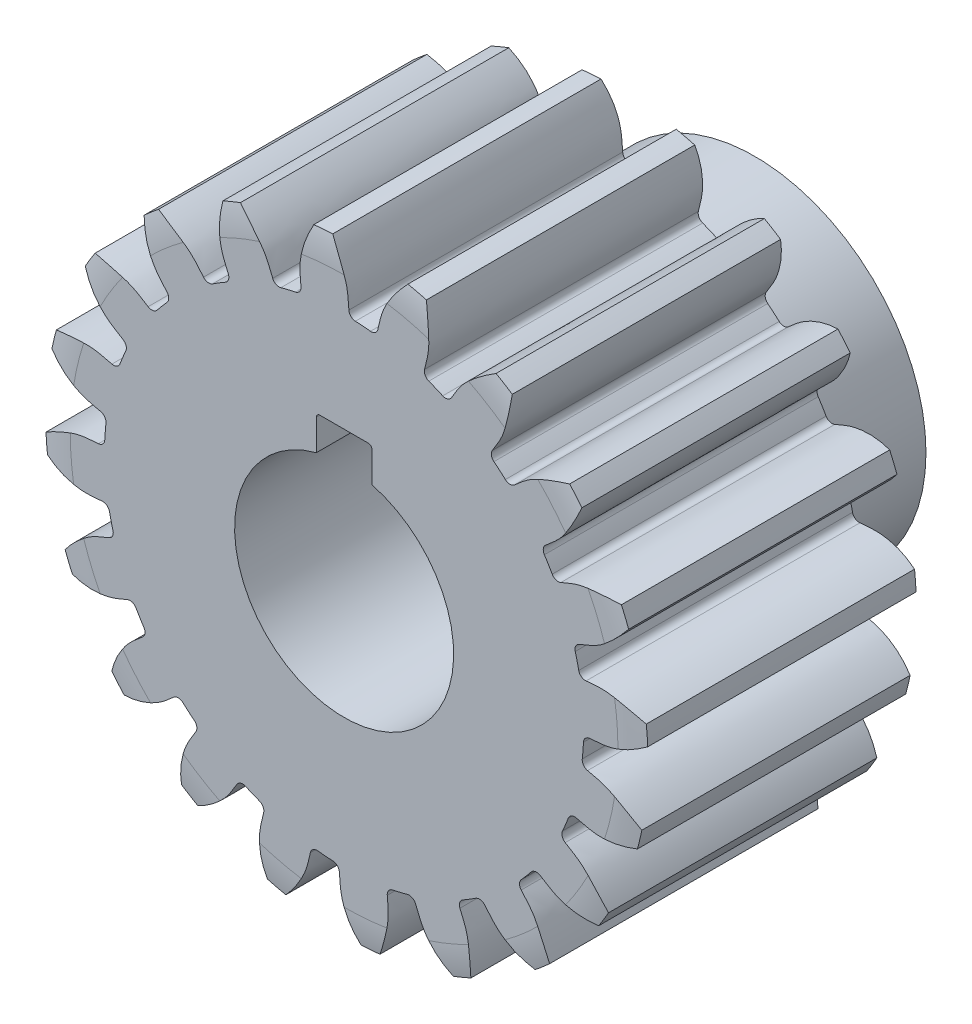
from build123d import *
from build123d.topology import SkipClean

# Parameters (mm, degrees)
SKETCH4_R                = 17.5
BOSS_EXTRUDE2_DEPTH      = 10
BOSS_EXTRUDE3_DEPTH      = 10
FILLET1_R                = 0.5
CIRPATTERN1_COUNT        = 20
FILLET1_OF_CIRPATTERN1_R = 0.5
CUT_EXTRUDE2_DEPTH       = 33.647621403
SKETCH9_R                = 8
CUT_EXTRUDE3_DEPTH       = 10
CUT_EXTRUDE4_DEPTH       = 10
BOSS_EXTRUDE4_START      = 10
SKETCH11_R               = 12.5
BOSS_EXTRUDE4_DEPTH      = 10
FILLET2_R                = 0.25
BOSS_EXTRUDE5_DEPTH      = 5
BOSS_EXTRUDE6_DEPTH      = 5
CUT_EXTRUDE5_START       = -39
CUT_EXTRUDE5_DEPTH       = 39


with BuildPart() as part:
    # Sketch4 → Boss-Extrude2 (new body)
    with BuildSketch(Plane.XY):
        Circle(SKETCH4_R)
    extrude(amount=BOSS_EXTRUDE2_DEPTH)

    # Sketch3 → Boss-Extrude3 (add)
    with BuildSketch(Plane.XY):
        with BuildLine():
            ThreePointArc((-1.03267312, 21.975749958), (-1.726100106, 21.932181342), (-2.417805488, 21.866737677))
            add(Edge.make_bspline(
                [(-3.114339189, 17.220653049), (-3.160079247, 17.912144851), (-3.298659823, 18.775292328), (-3.127363068, 19.784781367), (-3.009171352, 20.29468964), (-2.788912463, 21.006938533), (-2.572369364, 21.53562073), (-2.417805488, 21.866737677)],
                knots=[0, 0, 0, 0, 0.441913338, 0.532273099, 0.641803294, 0.770503925, 1, 1, 1, 1], degree=3))
            ThreePointArc((-3.114339189, 17.220653049), (-1.373034175, 17.44605334), (0.382092858, 17.495828218))
            add(Edge.make_bspline(
                [(0.382092858, 17.495828218), (0.31909663, 18.18596193), (0.320945035, 19.060161408), (-0.00616165, 20.030425246), (-0.202665458, 20.515566444), (-0.531632869, 21.18459029), (-0.82821408, 21.672888728), (-1.03267312, 21.975749958)],
                knots=[0, 0, 0, 0, 0.441913338, 0.532273099, 0.641803294, 0.770503925, 1, 1, 1, 1], degree=3))
        make_face()
    boss_extrude3 = extrude(amount=BOSS_EXTRUDE3_DEPTH)

    # Fillet1
    fillet1_edges = [part.edges().sort_by_distance(p)[0] for p in [
        (0.382092858, 17.495828218, 5),
        (-3.114339189, 17.220653049, 5),
    ]]
    fillet(fillet1_edges, radius=FILLET1_R)

    # CirPattern1: Boss-Extrude3 ×20 about axis
    cirpattern1_axis = Axis((0, 0, -86.49), (0, 0, 1))
    for i in range(1, CIRPATTERN1_COUNT):
        add(boss_extrude3.rotate(cirpattern1_axis, i * 360 / CIRPATTERN1_COUNT))

    # Fillet1 of CirPattern1
    fillet1_of_cirpattern1_edges = [part.edges().sort_by_distance(p)[0] for p in [
        (-5.043116348, 16.757594622, 5),
        (-8.283387026, 15.415430561, 5),
        (-9.974670188, 14.379010906, 5),
        (-12.641599227, 12.101238325, 5),
        (-13.929833812, 10.592909419, 5),
        (-15.762363616, 7.602492567, 5),
        (-16.521448249, 5.769900153, 5),
        (-17.340198032, 2.359561867, 5),
        (-17.495828218, 0.382092858, 5),
        (-17.220653049, -3.114339189, 5),
        (-16.757594622, -5.043116348, 5),
        (-15.415430561, -8.283387026, 5),
        (-14.379010906, -9.974670188, 5),
        (-12.101238325, -12.641599227, 5),
        (-10.592909419, -13.929833812, 5),
        (-7.602492567, -15.762363616, 5),
        (-5.769900153, -16.521448249, 5),
        (-2.359561867, -17.340198032, 5),
        (-0.382092858, -17.495828218, 5),
        (3.114339189, -17.220653049, 5),
        (5.043116348, -16.757594622, 5),
        (8.283387026, -15.415430561, 5),
        (9.974670188, -14.379010906, 5),
        (12.641599227, -12.101238325, 5),
        (13.929833812, -10.592909419, 5),
        (15.762363616, -7.602492567, 5),
        (16.521448249, -5.769900153, 5),
        (17.340198032, -2.359561867, 5),
        (17.495828218, -0.382092858, 5),
        (17.220653049, 3.114339189, 5),
        (16.757594622, 5.043116348, 5),
        (15.415430561, 8.283387026, 5),
        (14.379010906, 9.974670188, 5),
        (12.101238325, 12.641599227, 5),
        (10.592909419, 13.929833812, 5),
        (7.602492567, 15.762363616, 5),
        (5.769900153, 16.521448249, 5),
        (2.359561867, 17.340198032, 5),
    ]]
    fillet(fillet1_of_cirpattern1_edges, radius=FILLET1_OF_CIRPATTERN1_R)

    # Sketch5 → Cut-Extrude2 (cut, through all)
    with BuildSketch(Plane.XY):
        with BuildLine():
            Line((-1.4, 6.169696007), (1.4, 6.169696007))
            ThreePointArc((1.4, 6.169696007), (1.470710678, 6.140406685), (1.5, 6.069696007))
            Line((1.5, 6.069696007), (1.5, 4.769696007))
            ThreePointArc((1.5, 4.769696007), (0, -5), (-1.5, 4.769696007))
            Line((-1.5, 4.769696007), (-1.5, 6.069696007))
            ThreePointArc((-1.5, 6.069696007), (-1.470710678, 6.140406685), (-1.4, 6.169696007))
        make_face()
    extrude(amount=CUT_EXTRUDE2_DEPTH, mode=Mode.SUBTRACT)

    # Sketch7 → Cut-Revolve2 (revolve, cut)
    with BuildSketch(Plane(origin=(0, 0, 0), x_dir=(1, 0, 0), z_dir=(0, 1, 0))):
        with BuildLine():
            Line((-18, 0), (-20, 0))
            ThreePointArc((-20, 0), (-22.043096437, -0.210936871), (-24, -0.83484861))
            Line((-24, -0.83484861), (-24, 2))
            Line((-24, 2), (-18, 2))
            Line((-18, 2), (-18, 0))
        make_face()
    cut_revolve2 = revolve(axis=Axis((0, 0, -6.148940333), (0, 0, 1)), mode=Mode.SUBTRACT)

    # Sketch9 → Cut-Extrude3 (cut)
    with BuildSketch(Plane(origin=(0, 0, 0), x_dir=(-1, 0, 0), z_dir=(0, 0, -1))):
        Circle(SKETCH9_R)
    extrude(amount=-CUT_EXTRUDE3_DEPTH, mode=Mode.SUBTRACT)

    # Sketch10 → Cut-Extrude4 (cut)
    with BuildSketch(Plane(origin=(0, 0, 0), x_dir=(-1, 0, 0), z_dir=(0, 0, -1))):
        with BuildLine():
            Line((-2.025, 7.739468651), (-2.025, 10.239468651))
            Line((-2.025, 10.239468651), (2.025, 10.239468651))
            Line((2.025, 10.239468651), (2.025, 7.739468651))
            ThreePointArc((2.025, 7.739468651), (0, 8), (-2.025, 7.739468651))
        make_face()
    extrude(amount=-CUT_EXTRUDE4_DEPTH, mode=Mode.SUBTRACT)

    # Sketch11 → Boss-Extrude4 (add)
    with BuildSketch(Plane(origin=(0, 0, 0), x_dir=(-1, 0, 0), z_dir=(0, 0, -1)).offset(BOSS_EXTRUDE4_START)):
        with Locations(Location((0, 0, 0), (0, 0, 180))):
            Circle(SKETCH11_R)
        with BuildLine():
            Line((-2.025, 10.239468651), (-2.025, 7.739468651))
            ThreePointArc((-2.025, 7.739468651), (0, -8), (2.025, 7.739468651))
            Line((2.025, 7.739468651), (2.025, 10.239468651))
            Line((2.025, 10.239468651), (-2.025, 10.239468651))
        make_face(mode=Mode.SUBTRACT)
    extrude(amount=-BOSS_EXTRUDE4_DEPTH)

    # Fillet2
    fillet2_edges = [part.edges().sort_by_distance(p)[0] for p in [
        (2.025, 10.239468651, 0),
        (-2.025, 10.239468651, 0),
        (-12.5, 0, 0),
    ]]
    fillet(fillet2_edges, radius=FILLET2_R)

    # Sketch13 → Boss-Extrude5 (add)
    with SkipClean():  # the faces are left unmerged after this step: merging them gives an invalid solid
        with BuildSketch(Plane.XY.offset(10)):
            with BuildLine():
                ThreePointArc((-3.547592928, 17.136644491), (-3.247360967, 17.328397065), (-3.150990283, 17.671356204))
                add(Edge.make_bspline(
                    [(-2.417805488, 21.866737677), (-2.572369364, 21.53562073), (-2.788912463, 21.006938533), (-3.009171352, 20.29468964), (-3.127363068, 19.784781367), (-3.273209638, 18.925275802), (-3.200724929, 18.220572747), (-3.150990283, 17.671356204)],
                    knots=[0, 0, 0, 0, 0.229496075, 0.358196706, 0.467726901, 0.558086662, 0.904644941, 0.904644941, 0.904644941, 0.904644941], degree=3))
                ThreePointArc((-2.417805488, 21.866737677), (-1.726100106, 21.932181342), (-1.03267312, 21.975749958))
                add(Edge.make_bspline(
                    [(0.34778721, 17.946715965), (0.310993144, 18.496950953), (0.2723456, 19.20431705), (-0.00616165, 20.030425246), (-0.202665458, 20.515566444), (-0.531632869, 21.18459029), (-0.82821408, 21.672888728), (-1.03267312, 21.975749958)],
                    knots=[0.095355059, 0.095355059, 0.095355059, 0.095355059, 0.441913338, 0.532273099, 0.641803294, 0.770503925, 1, 1, 1, 1], degree=3))
                ThreePointArc((0.34778721, 17.946715965), (0.49662204, 17.623054918), (0.823154359, 17.480629763))
                ThreePointArc((0.823154359, 17.480629763), (1.373034175, 17.44605334), (1.921553003, 17.394183915))
                ThreePointArc((1.921553003, 17.394183915), (2.26634537, 17.483774671), (2.463979539, 17.780168016))
                add(Edge.make_bspline(
                    [(4.457723889, 21.543646342), (4.208404144, 21.276498277), (3.839087635, 20.840607126), (3.409511972, 20.231281915), (3.139534648, 19.782853579), (2.73522449, 19.010484278), (2.586396325, 18.317872839), (2.463979539, 17.780168016)],
                    knots=[0, 0, 0, 0, 0.229496075, 0.358196706, 0.467726901, 0.558086662, 0.904644941, 0.904644941, 0.904644941, 0.904644941], degree=3))
                ThreePointArc((4.457723889, 21.543646342), (5.135798005, 21.392138249), (5.808749701, 21.219293742))
                add(Edge.make_bspline(
                    [(5.876605518, 16.960869006), (6.011644244, 17.495543569), (6.193476392, 18.180231453), (6.183881728, 19.051970509), (6.146912376, 19.574090223), (6.040785514, 20.312026232), (5.909612537, 20.868074278), (5.808749701, 21.219293742)],
                    knots=[0.095355059, 0.095355059, 0.095355059, 0.095355059, 0.441913338, 0.532273099, 0.641803294, 0.770503925, 1, 1, 1, 1], degree=3))
                ThreePointArc((5.876605518, 16.960869006), (5.91813909, 16.607056566), (6.184677986, 16.370698159))
                ThreePointArc((6.184677986, 16.370698159), (6.696960066, 16.167891819), (7.202603938, 15.949059424))
                ThreePointArc((7.202603938, 15.949059424), (7.558206031, 15.927718596), (7.837757876, 16.148533101))
                add(Edge.make_bspline(
                    [(10.896900193, 19.111712801), (10.577229733, 18.934683931), (10.091291087, 18.634251889), (9.494448508, 18.187495357), (9.099112838, 17.844442246), (8.475915788, 17.2348141), (8.120343087, 16.622091909), (7.837757876, 16.148533101)],
                    knots=[0, 0, 0, 0, 0.229496075, 0.358196706, 0.467726901, 0.558086662, 0.904644941, 0.904644941, 0.904644941, 0.904644941], degree=3))
                ThreePointArc((10.896900193, 19.111712801), (11.494968424, 18.758083616), (12.08157163, 18.385745211))
                add(Edge.make_bspline(
                    [(10.830180734, 14.314774016), (11.123833721, 14.781550482), (11.508346561, 15.376538132), (11.768603677, 16.208576156), (11.894787599, 16.71656567), (12.021889723, 17.451179523), (12.068965104, 18.02054732), (12.08157163, 18.385745211)],
                    knots=[0.095355059, 0.095355059, 0.095355059, 0.095355059, 0.441913338, 0.532273099, 0.641803294, 0.770503925, 1, 1, 1, 1], degree=3))
                ThreePointArc((10.830180734, 14.314774016), (10.760347451, 13.96544381), (10.940802241, 13.658288558))
                ThreePointArc((10.940802241, 13.658288558), (11.365340846, 13.307104398), (11.778613816, 12.942729874))
                ThreePointArc((11.778613816, 12.942729874), (12.110216825, 12.81254645), (12.444321864, 12.936167253))
                add(Edge.make_bspline(
                    [(16.269411983, 14.808991651), (15.91068238, 14.739410796), (15.355688657, 14.603846244), (14.650002272, 14.363390033), (14.168006466, 14.159292577), (13.386925394, 13.772080235), (12.859414089, 13.299224811), (12.444321864, 12.936167253)],
                    knots=[0, 0, 0, 0, 0.229496075, 0.358196706, 0.467726901, 0.558086662, 0.904644941, 0.904644941, 0.904644941, 0.904644941], degree=3))
                ThreePointArc((16.269411983, 14.808991651), (16.728931243, 14.287857063), (17.17176515, 13.752471837))
                add(Edge.make_bspline(
                    [(14.723622401, 10.267449208), (15.147144848, 10.620636244), (15.696699586, 11.067682124), (16.201332702, 11.778573437), (16.478318135, 12.222707198), (16.826207604, 12.882089774), (17.046923277, 13.409043634), (17.17176515, 13.752471837)],
                    knots=[0.095355059, 0.095355059, 0.095355059, 0.095355059, 0.441913338, 0.532273099, 0.641803294, 0.770503925, 1, 1, 1, 1], degree=3))
                ThreePointArc((14.723622401, 10.267449208), (14.549258032, 9.956796111), (14.625964543, 9.60891051))
                ThreePointArc((14.625964543, 9.60891051), (14.921202876, 9.143724883), (15.201650907, 8.669475746))
                ThreePointArc((15.201650907, 8.669475746), (15.47679522, 8.443192987), (15.832748923, 8.457519222))
                add(Edge.make_bspline(
                    [(20.049360373, 9.056663218), (19.686686579, 9.101341436), (19.116964433, 9.143914378), (18.371511742, 9.133296017), (17.850036907, 9.088132697), (16.987529469, 8.961239201), (16.339716044, 8.674536927), (15.832748923, 8.457519222)],
                    knots=[0, 0, 0, 0, 0.229496075, 0.358196706, 0.467726901, 0.558086662, 0.904644941, 0.904644941, 0.904644941, 0.904644941], degree=3))
                ThreePointArc((20.049360373, 9.056663218), (20.325349715, 8.419035512), (20.581066654, 7.773010701))
                add(Edge.make_bspline(
                    [(17.175813322, 5.215074934), (17.687747902, 5.420100133), (18.348550291, 5.675444276), (19.0481624, 6.195601883), (19.448836082, 6.532404985), (19.983459049, 7.052011323), (20.356209826, 7.484969331), (20.581066654, 7.773010701)],
                    knots=[0.095355059, 0.095355059, 0.095355059, 0.095355059, 0.441913338, 0.532273099, 0.641803294, 0.770503925, 1, 1, 1, 1], degree=3))
                ThreePointArc((17.175813322, 5.215074934), (16.913985867, 4.973507835), (16.879435531, 4.618945352))
                ThreePointArc((16.879435531, 4.618945352), (17.016473607, 4.085293867), (17.136644491, 3.547592928))
                ThreePointArc((17.136644491, 3.547592928), (17.328397065, 3.247360967), (17.671356204, 3.150990283))
                add(Edge.make_bspline(
                    [(21.866737677, 2.417805488), (21.53562073, 2.572369364), (21.006938533, 2.788912463), (20.29468964, 3.009171352), (19.784781367, 3.127363068), (18.925275802, 3.273209638), (18.220572747, 3.200724929), (17.671356204, 3.150990283)],
                    knots=[0, 0, 0, 0, 0.229496075, 0.358196706, 0.467726901, 0.558086662, 0.904644941, 0.904644941, 0.904644941, 0.904644941], degree=3))
                ThreePointArc((21.866737677, 2.417805488), (21.932181342, 1.726100106), (21.975749958, 1.03267312))
                add(Edge.make_bspline(
                    [(17.946715965, -0.34778721), (18.496950953, -0.310993144), (19.20431705, -0.2723456), (20.030425246, 0.00616165), (20.515566444, 0.202665458), (21.18459029, 0.531632869), (21.672888728, 0.82821408), (21.975749958, 1.03267312)],
                    knots=[0.095355059, 0.095355059, 0.095355059, 0.095355059, 0.441913338, 0.532273099, 0.641803294, 0.770503925, 1, 1, 1, 1], degree=3))
                ThreePointArc((17.946715965, -0.34778721), (17.623054918, -0.49662204), (17.480629763, -0.823154359))
                ThreePointArc((17.480629763, -0.823154359), (17.44605334, -1.373034175), (17.394183915, -1.921553003))
                ThreePointArc((17.394183915, -1.921553003), (17.483774671, -2.26634537), (17.780168016, -2.463979539))
                add(Edge.make_bspline(
                    [(21.543646342, -4.457723889), (21.276498277, -4.208404144), (20.840607126, -3.839087635), (20.231281915, -3.409511972), (19.782853579, -3.139534648), (19.010484278, -2.73522449), (18.317872839, -2.586396325), (17.780168016, -2.463979539)],
                    knots=[0, 0, 0, 0, 0.229496075, 0.358196706, 0.467726901, 0.558086662, 0.904644941, 0.904644941, 0.904644941, 0.904644941], degree=3))
                ThreePointArc((21.543646342, -4.457723889), (21.392138249, -5.135798005), (21.219293742, -5.808749701))
                add(Edge.make_bspline(
                    [(16.960869006, -5.876605518), (17.495543569, -6.011644244), (18.180231453, -6.193476392), (19.051970509, -6.183881728), (19.574090223, -6.146912376), (20.312026232, -6.040785514), (20.868074278, -5.909612537), (21.219293742, -5.808749701)],
                    knots=[0.095355059, 0.095355059, 0.095355059, 0.095355059, 0.441913338, 0.532273099, 0.641803294, 0.770503925, 1, 1, 1, 1], degree=3))
                ThreePointArc((16.960869006, -5.876605518), (16.607056566, -5.91813909), (16.370698159, -6.184677986))
                ThreePointArc((16.370698159, -6.184677986), (16.167891819, -6.696960066), (15.949059424, -7.202603938))
                ThreePointArc((15.949059424, -7.202603938), (15.927718596, -7.558206031), (16.148533101, -7.837757876))
                add(Edge.make_bspline(
                    [(19.111712801, -10.896900193), (18.934683931, -10.577229733), (18.634251889, -10.091291087), (18.187495357, -9.494448508), (17.844442246, -9.099112838), (17.2348141, -8.475915788), (16.622091909, -8.120343087), (16.148533101, -7.837757876)],
                    knots=[0, 0, 0, 0, 0.229496075, 0.358196706, 0.467726901, 0.558086662, 0.904644941, 0.904644941, 0.904644941, 0.904644941], degree=3))
                ThreePointArc((19.111712801, -10.896900193), (18.758083616, -11.494968424), (18.385745211, -12.08157163))
                add(Edge.make_bspline(
                    [(14.314774016, -10.830180734), (14.781550482, -11.123833721), (15.376538132, -11.508346561), (16.208576156, -11.768603677), (16.71656567, -11.894787599), (17.451179523, -12.021889723), (18.02054732, -12.068965104), (18.385745211, -12.08157163)],
                    knots=[0.095355059, 0.095355059, 0.095355059, 0.095355059, 0.441913338, 0.532273099, 0.641803294, 0.770503925, 1, 1, 1, 1], degree=3))
                ThreePointArc((14.314774016, -10.830180734), (13.96544381, -10.760347451), (13.658288558, -10.940802241))
                ThreePointArc((13.658288558, -10.940802241), (13.307104398, -11.365340846), (12.942729874, -11.778613816))
                ThreePointArc((12.942729874, -11.778613816), (12.81254645, -12.110216825), (12.936167253, -12.444321864))
                add(Edge.make_bspline(
                    [(14.808991651, -16.269411983), (14.739410796, -15.91068238), (14.603846244, -15.355688657), (14.363390033, -14.650002272), (14.159292577, -14.168006466), (13.772080235, -13.386925394), (13.299224811, -12.859414089), (12.936167253, -12.444321864)],
                    knots=[0, 0, 0, 0, 0.229496075, 0.358196706, 0.467726901, 0.558086662, 0.904644941, 0.904644941, 0.904644941, 0.904644941], degree=3))
                ThreePointArc((14.808991651, -16.269411983), (14.287857063, -16.728931243), (13.752471837, -17.17176515))
                add(Edge.make_bspline(
                    [(10.267449208, -14.723622401), (10.620636244, -15.147144848), (11.067682124, -15.696699586), (11.778573437, -16.201332702), (12.222707198, -16.478318135), (12.882089774, -16.826207604), (13.409043634, -17.046923277), (13.752471837, -17.17176515)],
                    knots=[0.095355059, 0.095355059, 0.095355059, 0.095355059, 0.441913338, 0.532273099, 0.641803294, 0.770503925, 1, 1, 1, 1], degree=3))
                ThreePointArc((10.267449208, -14.723622401), (9.956796111, -14.549258032), (9.60891051, -14.625964543))
                ThreePointArc((9.60891051, -14.625964543), (9.143724883, -14.921202876), (8.669475746, -15.201650907))
                ThreePointArc((8.669475746, -15.201650907), (8.443192987, -15.47679522), (8.457519222, -15.832748923))
                add(Edge.make_bspline(
                    [(9.056663218, -20.049360373), (9.101341436, -19.686686579), (9.143914378, -19.116964433), (9.133296017, -18.371511742), (9.088132697, -17.850036907), (8.961239201, -16.987529469), (8.674536927, -16.339716044), (8.457519222, -15.832748923)],
                    knots=[0, 0, 0, 0, 0.229496075, 0.358196706, 0.467726901, 0.558086662, 0.904644941, 0.904644941, 0.904644941, 0.904644941], degree=3))
                ThreePointArc((9.056663218, -20.049360373), (8.419035512, -20.325349715), (7.773010701, -20.581066654))
                add(Edge.make_bspline(
                    [(5.215074934, -17.175813322), (5.420100133, -17.687747902), (5.675444276, -18.348550291), (6.195601883, -19.0481624), (6.532404985, -19.448836082), (7.052011323, -19.983459049), (7.484969331, -20.356209826), (7.773010701, -20.581066654)],
                    knots=[0.095355059, 0.095355059, 0.095355059, 0.095355059, 0.441913338, 0.532273099, 0.641803294, 0.770503925, 1, 1, 1, 1], degree=3))
                ThreePointArc((5.215074934, -17.175813322), (4.973507835, -16.913985867), (4.618945352, -16.879435531))
                ThreePointArc((4.618945352, -16.879435531), (4.085293867, -17.016473607), (3.547592928, -17.136644491))
                ThreePointArc((3.547592928, -17.136644491), (3.247360967, -17.328397065), (3.150990283, -17.671356204))
                add(Edge.make_bspline(
                    [(2.417805488, -21.866737677), (2.572369364, -21.53562073), (2.788912463, -21.006938533), (3.009171352, -20.29468964), (3.127363068, -19.784781367), (3.273209638, -18.925275802), (3.200724929, -18.220572747), (3.150990283, -17.671356204)],
                    knots=[0, 0, 0, 0, 0.229496075, 0.358196706, 0.467726901, 0.558086662, 0.904644941, 0.904644941, 0.904644941, 0.904644941], degree=3))
                ThreePointArc((2.417805488, -21.866737677), (1.726100106, -21.932181342), (1.03267312, -21.975749958))
                add(Edge.make_bspline(
                    [(-0.34778721, -17.946715965), (-0.310993144, -18.496950953), (-0.2723456, -19.20431705), (0.00616165, -20.030425246), (0.202665458, -20.515566444), (0.531632869, -21.18459029), (0.82821408, -21.672888728), (1.03267312, -21.975749958)],
                    knots=[0.095355059, 0.095355059, 0.095355059, 0.095355059, 0.441913338, 0.532273099, 0.641803294, 0.770503925, 1, 1, 1, 1], degree=3))
                ThreePointArc((-0.34778721, -17.946715965), (-0.49662204, -17.623054918), (-0.823154359, -17.480629763))
                ThreePointArc((-0.823154359, -17.480629763), (-1.373034175, -17.44605334), (-1.921553003, -17.394183915))
                ThreePointArc((-1.921553003, -17.394183915), (-2.26634537, -17.483774671), (-2.463979539, -17.780168016))
                add(Edge.make_bspline(
                    [(-4.457723889, -21.543646342), (-4.208404144, -21.276498277), (-3.839087635, -20.840607126), (-3.409511972, -20.231281915), (-3.139534648, -19.782853579), (-2.73522449, -19.010484278), (-2.586396325, -18.317872839), (-2.463979539, -17.780168016)],
                    knots=[0, 0, 0, 0, 0.229496075, 0.358196706, 0.467726901, 0.558086662, 0.904644941, 0.904644941, 0.904644941, 0.904644941], degree=3))
                ThreePointArc((-4.457723889, -21.543646342), (-5.135798005, -21.392138249), (-5.808749701, -21.219293742))
                add(Edge.make_bspline(
                    [(-5.876605518, -16.960869006), (-6.011644244, -17.495543569), (-6.193476392, -18.180231453), (-6.183881728, -19.051970509), (-6.146912376, -19.574090223), (-6.040785514, -20.312026232), (-5.909612537, -20.868074278), (-5.808749701, -21.219293742)],
                    knots=[0.095355059, 0.095355059, 0.095355059, 0.095355059, 0.441913338, 0.532273099, 0.641803294, 0.770503925, 1, 1, 1, 1], degree=3))
                ThreePointArc((-5.876605518, -16.960869006), (-5.91813909, -16.607056566), (-6.184677986, -16.370698159))
                ThreePointArc((-6.184677986, -16.370698159), (-6.696960066, -16.167891819), (-7.202603938, -15.949059424))
                ThreePointArc((-7.202603938, -15.949059424), (-7.558206031, -15.927718596), (-7.837757876, -16.148533101))
                add(Edge.make_bspline(
                    [(-10.896900193, -19.111712801), (-10.577229733, -18.934683931), (-10.091291087, -18.634251889), (-9.494448508, -18.187495357), (-9.099112838, -17.844442246), (-8.475915788, -17.2348141), (-8.120343087, -16.622091909), (-7.837757876, -16.148533101)],
                    knots=[0, 0, 0, 0, 0.229496075, 0.358196706, 0.467726901, 0.558086662, 0.904644941, 0.904644941, 0.904644941, 0.904644941], degree=3))
                ThreePointArc((-10.896900193, -19.111712801), (-11.494968424, -18.758083616), (-12.08157163, -18.385745211))
                add(Edge.make_bspline(
                    [(-10.830180734, -14.314774016), (-11.123833721, -14.781550482), (-11.508346561, -15.376538132), (-11.768603677, -16.208576156), (-11.894787599, -16.71656567), (-12.021889723, -17.451179523), (-12.068965104, -18.02054732), (-12.08157163, -18.385745211)],
                    knots=[0.095355059, 0.095355059, 0.095355059, 0.095355059, 0.441913338, 0.532273099, 0.641803294, 0.770503925, 1, 1, 1, 1], degree=3))
                ThreePointArc((-10.830180734, -14.314774016), (-10.760347451, -13.96544381), (-10.940802241, -13.658288558))
                ThreePointArc((-10.940802241, -13.658288558), (-11.365340846, -13.307104398), (-11.778613816, -12.942729874))
                ThreePointArc((-11.778613816, -12.942729874), (-12.110216825, -12.81254645), (-12.444321864, -12.936167253))
                add(Edge.make_bspline(
                    [(-16.269411983, -14.808991651), (-15.91068238, -14.739410796), (-15.355688657, -14.603846244), (-14.650002272, -14.363390033), (-14.168006466, -14.159292577), (-13.386925394, -13.772080235), (-12.859414089, -13.299224811), (-12.444321864, -12.936167253)],
                    knots=[0, 0, 0, 0, 0.229496075, 0.358196706, 0.467726901, 0.558086662, 0.904644941, 0.904644941, 0.904644941, 0.904644941], degree=3))
                ThreePointArc((-16.269411983, -14.808991651), (-16.728931243, -14.287857063), (-17.17176515, -13.752471837))
                add(Edge.make_bspline(
                    [(-14.723622401, -10.267449208), (-15.147144848, -10.620636244), (-15.696699586, -11.067682124), (-16.201332702, -11.778573437), (-16.478318135, -12.222707198), (-16.826207604, -12.882089774), (-17.046923277, -13.409043634), (-17.17176515, -13.752471837)],
                    knots=[0.095355059, 0.095355059, 0.095355059, 0.095355059, 0.441913338, 0.532273099, 0.641803294, 0.770503925, 1, 1, 1, 1], degree=3))
                ThreePointArc((-14.723622401, -10.267449208), (-14.549258032, -9.956796111), (-14.625964543, -9.60891051))
                ThreePointArc((-14.625964543, -9.60891051), (-14.921202876, -9.143724883), (-15.201650907, -8.669475746))
                ThreePointArc((-15.201650907, -8.669475746), (-15.47679522, -8.443192987), (-15.832748923, -8.457519222))
                add(Edge.make_bspline(
                    [(-20.049360373, -9.056663218), (-19.686686579, -9.101341436), (-19.116964433, -9.143914378), (-18.371511742, -9.133296017), (-17.850036907, -9.088132697), (-16.987529469, -8.961239201), (-16.339716044, -8.674536927), (-15.832748923, -8.457519222)],
                    knots=[0, 0, 0, 0, 0.229496075, 0.358196706, 0.467726901, 0.558086662, 0.904644941, 0.904644941, 0.904644941, 0.904644941], degree=3))
                ThreePointArc((-20.049360373, -9.056663218), (-20.325349715, -8.419035512), (-20.581066654, -7.773010701))
                add(Edge.make_bspline(
                    [(-17.175813322, -5.215074934), (-17.687747902, -5.420100133), (-18.348550291, -5.675444276), (-19.0481624, -6.195601883), (-19.448836082, -6.532404985), (-19.983459049, -7.052011323), (-20.356209826, -7.484969331), (-20.581066654, -7.773010701)],
                    knots=[0.095355059, 0.095355059, 0.095355059, 0.095355059, 0.441913338, 0.532273099, 0.641803294, 0.770503925, 1, 1, 1, 1], degree=3))
                ThreePointArc((-17.175813322, -5.215074934), (-16.913985867, -4.973507835), (-16.879435531, -4.618945352))
                ThreePointArc((-16.879435531, -4.618945352), (-17.016473607, -4.085293867), (-17.136644491, -3.547592928))
                ThreePointArc((-17.136644491, -3.547592928), (-17.328397065, -3.247360967), (-17.671356204, -3.150990283))
                add(Edge.make_bspline(
                    [(-21.866737677, -2.417805488), (-21.53562073, -2.572369364), (-21.006938533, -2.788912463), (-20.29468964, -3.009171352), (-19.784781367, -3.127363068), (-18.925275802, -3.273209638), (-18.220572747, -3.200724929), (-17.671356204, -3.150990283)],
                    knots=[0, 0, 0, 0, 0.229496075, 0.358196706, 0.467726901, 0.558086662, 0.904644941, 0.904644941, 0.904644941, 0.904644941], degree=3))
                ThreePointArc((-21.866737677, -2.417805488), (-21.932181342, -1.726100106), (-21.975749958, -1.03267312))
                add(Edge.make_bspline(
                    [(-17.946715965, 0.34778721), (-18.496950953, 0.310993144), (-19.20431705, 0.2723456), (-20.030425246, -0.00616165), (-20.515566444, -0.202665458), (-21.18459029, -0.531632869), (-21.672888728, -0.82821408), (-21.975749958, -1.03267312)],
                    knots=[0.095355059, 0.095355059, 0.095355059, 0.095355059, 0.441913338, 0.532273099, 0.641803294, 0.770503925, 1, 1, 1, 1], degree=3))
                ThreePointArc((-17.946715965, 0.34778721), (-17.623054918, 0.49662204), (-17.480629763, 0.823154359))
                ThreePointArc((-17.480629763, 0.823154359), (-17.44605334, 1.373034175), (-17.394183915, 1.921553003))
                ThreePointArc((-17.394183915, 1.921553003), (-17.483774671, 2.26634537), (-17.780168016, 2.463979539))
                add(Edge.make_bspline(
                    [(-21.543646342, 4.457723889), (-21.276498277, 4.208404144), (-20.840607126, 3.839087635), (-20.231281915, 3.409511972), (-19.782853579, 3.139534648), (-19.010484278, 2.73522449), (-18.317872839, 2.586396325), (-17.780168016, 2.463979539)],
                    knots=[0, 0, 0, 0, 0.229496075, 0.358196706, 0.467726901, 0.558086662, 0.904644941, 0.904644941, 0.904644941, 0.904644941], degree=3))
                ThreePointArc((-21.543646342, 4.457723889), (-21.392138249, 5.135798005), (-21.219293742, 5.808749701))
                add(Edge.make_bspline(
                    [(-16.960869006, 5.876605518), (-17.495543569, 6.011644244), (-18.180231453, 6.193476392), (-19.051970509, 6.183881728), (-19.574090223, 6.146912376), (-20.312026232, 6.040785514), (-20.868074278, 5.909612537), (-21.219293742, 5.808749701)],
                    knots=[0.095355059, 0.095355059, 0.095355059, 0.095355059, 0.441913338, 0.532273099, 0.641803294, 0.770503925, 1, 1, 1, 1], degree=3))
                ThreePointArc((-16.960869006, 5.876605518), (-16.607056566, 5.91813909), (-16.370698159, 6.184677986))
                ThreePointArc((-16.370698159, 6.184677986), (-16.167891819, 6.696960066), (-15.949059424, 7.202603938))
                ThreePointArc((-15.949059424, 7.202603938), (-15.927718596, 7.558206031), (-16.148533101, 7.837757876))
                add(Edge.make_bspline(
                    [(-19.111712801, 10.896900193), (-18.934683931, 10.577229733), (-18.634251889, 10.091291087), (-18.187495357, 9.494448508), (-17.844442246, 9.099112838), (-17.2348141, 8.475915788), (-16.622091909, 8.120343087), (-16.148533101, 7.837757876)],
                    knots=[0, 0, 0, 0, 0.229496075, 0.358196706, 0.467726901, 0.558086662, 0.904644941, 0.904644941, 0.904644941, 0.904644941], degree=3))
                ThreePointArc((-19.111712801, 10.896900193), (-18.758083616, 11.494968424), (-18.385745211, 12.08157163))
                add(Edge.make_bspline(
                    [(-14.314774016, 10.830180734), (-14.781550482, 11.123833721), (-15.376538132, 11.508346561), (-16.208576156, 11.768603677), (-16.71656567, 11.894787599), (-17.451179523, 12.021889723), (-18.02054732, 12.068965104), (-18.385745211, 12.08157163)],
                    knots=[0.095355059, 0.095355059, 0.095355059, 0.095355059, 0.441913338, 0.532273099, 0.641803294, 0.770503925, 1, 1, 1, 1], degree=3))
                ThreePointArc((-14.314774016, 10.830180734), (-13.96544381, 10.760347451), (-13.658288558, 10.940802241))
                ThreePointArc((-13.658288558, 10.940802241), (-13.307104398, 11.365340846), (-12.942729874, 11.778613816))
                ThreePointArc((-12.942729874, 11.778613816), (-12.81254645, 12.110216825), (-12.936167253, 12.444321864))
                add(Edge.make_bspline(
                    [(-14.808991651, 16.269411983), (-14.739410796, 15.91068238), (-14.603846244, 15.355688657), (-14.363390033, 14.650002272), (-14.159292577, 14.168006466), (-13.772080235, 13.386925394), (-13.299224811, 12.859414089), (-12.936167253, 12.444321864)],
                    knots=[0, 0, 0, 0, 0.229496075, 0.358196706, 0.467726901, 0.558086662, 0.904644941, 0.904644941, 0.904644941, 0.904644941], degree=3))
                ThreePointArc((-14.808991651, 16.269411983), (-14.287857063, 16.728931243), (-13.752471837, 17.17176515))
                add(Edge.make_bspline(
                    [(-10.267449208, 14.723622401), (-10.620636244, 15.147144848), (-11.067682124, 15.696699586), (-11.778573437, 16.201332702), (-12.222707198, 16.478318135), (-12.882089774, 16.826207604), (-13.409043634, 17.046923277), (-13.752471837, 17.17176515)],
                    knots=[0.095355059, 0.095355059, 0.095355059, 0.095355059, 0.441913338, 0.532273099, 0.641803294, 0.770503925, 1, 1, 1, 1], degree=3))
                ThreePointArc((-10.267449208, 14.723622401), (-9.956796111, 14.549258032), (-9.60891051, 14.625964543))
                ThreePointArc((-9.60891051, 14.625964543), (-9.143724883, 14.921202876), (-8.669475746, 15.201650907))
                ThreePointArc((-8.669475746, 15.201650907), (-8.443192987, 15.47679522), (-8.457519222, 15.832748923))
                add(Edge.make_bspline(
                    [(-9.056663218, 20.049360373), (-9.101341436, 19.686686579), (-9.143914378, 19.116964433), (-9.133296017, 18.371511742), (-9.088132697, 17.850036907), (-8.961239201, 16.987529469), (-8.674536927, 16.339716044), (-8.457519222, 15.832748923)],
                    knots=[0, 0, 0, 0, 0.229496075, 0.358196706, 0.467726901, 0.558086662, 0.904644941, 0.904644941, 0.904644941, 0.904644941], degree=3))
                ThreePointArc((-9.056663218, 20.049360373), (-8.419035512, 20.325349715), (-7.773010701, 20.581066654))
                add(Edge.make_bspline(
                    [(-5.215074934, 17.175813322), (-5.420100133, 17.687747902), (-5.675444276, 18.348550291), (-6.195601883, 19.0481624), (-6.532404985, 19.448836082), (-7.052011323, 19.983459049), (-7.484969331, 20.356209826), (-7.773010701, 20.581066654)],
                    knots=[0.095355059, 0.095355059, 0.095355059, 0.095355059, 0.441913338, 0.532273099, 0.641803294, 0.770503925, 1, 1, 1, 1], degree=3))
                ThreePointArc((-5.215074934, 17.175813322), (-4.973507835, 16.913985867), (-4.618945352, 16.879435531))
                ThreePointArc((-4.618945352, 16.879435531), (-4.085293867, 17.016473607), (-3.547592928, 17.136644491))
            make_face()
            with BuildLine():
                Line((-2.025, 9.989468651), (-2.025, 7.739468651))
                ThreePointArc((-2.025, 7.739468651), (0, -8), (2.025, 7.739468651))
                Line((2.025, 7.739468651), (2.025, 9.989468651))
                ThreePointArc((2.025, 9.989468651), (1.951776695, 10.166245346), (1.775, 10.239468651))
                Line((1.775, 10.239468651), (-1.775, 10.239468651))
                ThreePointArc((-1.775, 10.239468651), (-1.951776695, 10.166245346), (-2.025, 9.989468651))
            make_face(mode=Mode.SUBTRACT)
        extrude(amount=BOSS_EXTRUDE5_DEPTH)

    # Sketch14 → Boss-Extrude6 (add)
    with BuildSketch(Plane.XY.offset(15)):
        with BuildLine():
            ThreePointArc((-3.547592928, 17.136644491), (-3.24736099, 17.328397034), (-3.150990276, 17.671356128))
            add(Edge.make_bspline(
                [(-2.417805488, 21.866737677), (-2.572369364, 21.53562073), (-2.788912463, 21.006938533), (-3.009171352, 20.29468964), (-3.127363068, 19.784781367), (-3.273209642, 18.925275776), (-3.200724924, 18.220572695), (-3.150990276, 17.671356128)],
                knots=[0, 0, 0, 0, 0.229496075, 0.358196706, 0.467726901, 0.558086662, 0.904644957, 0.904644957, 0.904644957, 0.904644957], degree=3))
            ThreePointArc((-2.417805488, 21.866737677), (-1.726100106, 21.932181342), (-1.03267312, 21.975749958))
            add(Edge.make_bspline(
                [(0.34778721, 17.946715965), (0.310993146, 18.496950901), (0.272345608, 19.204317026), (-0.00616165, 20.030425246), (-0.202665458, 20.515566444), (-0.531632869, 21.18459029), (-0.82821408, 21.672888728), (-1.03267312, 21.975749958)],
                knots=[0.095355059, 0.095355059, 0.095355059, 0.095355059, 0.441913338, 0.532273099, 0.641803294, 0.770503925, 1, 1, 1, 1], degree=3))
            ThreePointArc((0.34778721, 17.946715965), (0.49662204, 17.623054918), (0.823154359, 17.480629763))
            ThreePointArc((0.823154359, 17.480629763), (1.373034175, 17.44605334), (1.921553003, 17.394183915))
            ThreePointArc((1.921553003, 17.394183915), (2.266345339, 17.483774649), (2.463979522, 17.780167942))
            add(Edge.make_bspline(
                [(4.457723889, 21.543646342), (4.208404144, 21.276498277), (3.839087635, 20.840607126), (3.409511972, 20.231281915), (3.139534648, 19.782853579), (2.735224478, 19.010484255), (2.586396314, 18.317872788), (2.463979522, 17.780167942)],
                knots=[0, 0, 0, 0, 0.229496075, 0.358196706, 0.467726901, 0.558086662, 0.904644957, 0.904644957, 0.904644957, 0.904644957], degree=3))
            ThreePointArc((4.457723889, 21.543646342), (5.135798005, 21.392138249), (5.808749701, 21.219293742))
            add(Edge.make_bspline(
                [(5.876605518, 16.960869006), (6.011644231, 17.495543518), (6.193476392, 18.180231427), (6.183881728, 19.051970509), (6.146912376, 19.574090223), (6.040785514, 20.312026232), (5.909612537, 20.868074278), (5.808749701, 21.219293742)],
                knots=[0.095355059, 0.095355059, 0.095355059, 0.095355059, 0.441913338, 0.532273099, 0.641803294, 0.770503925, 1, 1, 1, 1], degree=3))
            ThreePointArc((5.876605518, 16.960869006), (5.91813909, 16.607056566), (6.184677986, 16.370698159))
            ThreePointArc((6.184677986, 16.370698159), (6.696960066, 16.167891819), (7.202603938, 15.949059424))
            ThreePointArc((7.202603938, 15.949059424), (7.558205995, 15.927718584), (7.837757837, 16.148533036))
            add(Edge.make_bspline(
                [(10.896900193, 19.111712801), (10.577229733, 18.934683931), (10.091291087, 18.634251889), (9.494448508, 18.187495357), (9.099112838, 17.844442246), (8.47591577, 17.234814082), (8.120343061, 16.622091864), (7.837757837, 16.148533036)],
                knots=[0, 0, 0, 0, 0.229496075, 0.358196706, 0.467726901, 0.558086662, 0.904644957, 0.904644957, 0.904644957, 0.904644957], degree=3))
            ThreePointArc((10.896900193, 19.111712801), (11.494968424, 18.758083616), (12.08157163, 18.385745211))
            add(Edge.make_bspline(
                [(10.830180734, 14.314774016), (11.123833692, 14.781550438), (11.508346554, 15.376538107), (11.768603677, 16.208576156), (11.894787599, 16.71656567), (12.021889723, 17.451179523), (12.068965104, 18.02054732), (12.08157163, 18.385745211)],
                knots=[0.095355059, 0.095355059, 0.095355059, 0.095355059, 0.441913338, 0.532273099, 0.641803294, 0.770503925, 1, 1, 1, 1], degree=3))
            ThreePointArc((10.830180734, 14.314774016), (10.760347451, 13.96544381), (10.940802241, 13.658288558))
            ThreePointArc((10.940802241, 13.658288558), (11.365340846, 13.307104398), (11.778613816, 12.942729874))
            ThreePointArc((11.778613816, 12.942729874), (12.110216787, 12.81254645), (12.444321806, 12.936167203))
            add(Edge.make_bspline(
                [(16.269411983, 14.808991651), (15.91068238, 14.739410796), (15.355688657, 14.603846244), (14.650002272, 14.363390033), (14.168006466, 14.159292577), (13.386925371, 13.772080224), (12.85941405, 13.299224776), (12.444321806, 12.936167203)],
                knots=[0, 0, 0, 0, 0.229496075, 0.358196706, 0.467726901, 0.558086662, 0.904644957, 0.904644957, 0.904644957, 0.904644957], degree=3))
            ThreePointArc((16.269411983, 14.808991651), (16.728931243, 14.287857063), (17.17176515, 13.752471837))
            add(Edge.make_bspline(
                [(14.723622401, 10.267449208), (15.147144808, 10.620636211), (15.696699572, 11.067682103), (16.201332702, 11.778573437), (16.478318135, 12.222707198), (16.826207604, 12.882089774), (17.046923277, 13.409043634), (17.17176515, 13.752471837)],
                knots=[0.095355059, 0.095355059, 0.095355059, 0.095355059, 0.441913338, 0.532273099, 0.641803294, 0.770503925, 1, 1, 1, 1], degree=3))
            ThreePointArc((14.723622401, 10.267449208), (14.549258032, 9.956796111), (14.625964543, 9.60891051))
            ThreePointArc((14.625964543, 9.60891051), (14.921202876, 9.143724883), (15.201650907, 8.669475746))
            ThreePointArc((15.201650907, 8.669475746), (15.476795183, 8.443192999), (15.832748853, 8.457519192))
            add(Edge.make_bspline(
                [(20.049360373, 9.056663218), (19.686686579, 9.101341436), (19.116964433, 9.143914378), (18.371511742, 9.133296017), (17.850036907, 9.088132697), (16.987529444, 8.961239198), (16.339715996, 8.674536906), (15.832748853, 8.457519192)],
                knots=[0, 0, 0, 0, 0.229496075, 0.358196706, 0.467726901, 0.558086662, 0.904644957, 0.904644957, 0.904644957, 0.904644957], degree=3))
            ThreePointArc((20.049360373, 9.056663218), (20.325349715, 8.419035512), (20.581066654, 7.773010701))
            add(Edge.make_bspline(
                [(17.175813322, 5.215074934), (17.687747853, 5.420100114), (18.34855027, 5.675444261), (19.0481624, 6.195601883), (19.448836082, 6.532404985), (19.983459049, 7.052011323), (20.356209826, 7.484969331), (20.581066654, 7.773010701)],
                knots=[0.095355059, 0.095355059, 0.095355059, 0.095355059, 0.441913338, 0.532273099, 0.641803294, 0.770503925, 1, 1, 1, 1], degree=3))
            ThreePointArc((17.175813322, 5.215074934), (16.913985867, 4.973507835), (16.879435531, 4.618945352))
            ThreePointArc((16.879435531, 4.618945352), (17.016473607, 4.085293867), (17.136644491, 3.547592928))
            ThreePointArc((17.136644491, 3.547592928), (17.328397034, 3.24736099), (17.671356128, 3.150990276))
            add(Edge.make_bspline(
                [(21.866737677, 2.417805488), (21.53562073, 2.572369364), (21.006938533, 2.788912463), (20.29468964, 3.009171352), (19.784781367, 3.127363068), (18.925275776, 3.273209642), (18.220572695, 3.200724924), (17.671356128, 3.150990276)],
                knots=[0, 0, 0, 0, 0.229496075, 0.358196706, 0.467726901, 0.558086662, 0.904644957, 0.904644957, 0.904644957, 0.904644957], degree=3))
            ThreePointArc((21.866737677, 2.417805488), (21.932181342, 1.726100106), (21.975749958, 1.03267312))
            add(Edge.make_bspline(
                [(17.946715965, -0.34778721), (18.496950901, -0.310993146), (19.204317026, -0.272345608), (20.030425246, 0.00616165), (20.515566444, 0.202665458), (21.18459029, 0.531632869), (21.672888728, 0.82821408), (21.975749958, 1.03267312)],
                knots=[0.095355059, 0.095355059, 0.095355059, 0.095355059, 0.441913338, 0.532273099, 0.641803294, 0.770503925, 1, 1, 1, 1], degree=3))
            ThreePointArc((17.946715965, -0.34778721), (17.623054918, -0.49662204), (17.480629763, -0.823154359))
            ThreePointArc((17.480629763, -0.823154359), (17.44605334, -1.373034175), (17.394183915, -1.921553003))
            ThreePointArc((17.394183915, -1.921553003), (17.483774649, -2.266345339), (17.780167942, -2.463979522))
            add(Edge.make_bspline(
                [(21.543646342, -4.457723889), (21.276498277, -4.208404144), (20.840607126, -3.839087635), (20.231281915, -3.409511972), (19.782853579, -3.139534648), (19.010484255, -2.735224478), (18.317872788, -2.586396314), (17.780167942, -2.463979522)],
                knots=[0, 0, 0, 0, 0.229496075, 0.358196706, 0.467726901, 0.558086662, 0.904644957, 0.904644957, 0.904644957, 0.904644957], degree=3))
            ThreePointArc((21.543646342, -4.457723889), (21.392138249, -5.135798005), (21.219293742, -5.808749701))
            add(Edge.make_bspline(
                [(16.960869006, -5.876605518), (17.495543518, -6.011644231), (18.180231427, -6.193476392), (19.051970509, -6.183881728), (19.574090223, -6.146912376), (20.312026232, -6.040785514), (20.868074278, -5.909612537), (21.219293742, -5.808749701)],
                knots=[0.095355059, 0.095355059, 0.095355059, 0.095355059, 0.441913338, 0.532273099, 0.641803294, 0.770503925, 1, 1, 1, 1], degree=3))
            ThreePointArc((16.960869006, -5.876605518), (16.607056566, -5.91813909), (16.370698159, -6.184677986))
            ThreePointArc((16.370698159, -6.184677986), (16.167891819, -6.696960066), (15.949059424, -7.202603938))
            ThreePointArc((15.949059424, -7.202603938), (15.927718584, -7.558205995), (16.148533036, -7.837757837))
            add(Edge.make_bspline(
                [(19.111712801, -10.896900193), (18.934683931, -10.577229733), (18.634251889, -10.091291087), (18.187495357, -9.494448508), (17.844442246, -9.099112838), (17.234814082, -8.47591577), (16.622091864, -8.120343061), (16.148533036, -7.837757837)],
                knots=[0, 0, 0, 0, 0.229496075, 0.358196706, 0.467726901, 0.558086662, 0.904644957, 0.904644957, 0.904644957, 0.904644957], degree=3))
            ThreePointArc((19.111712801, -10.896900193), (18.758083616, -11.494968424), (18.385745211, -12.08157163))
            add(Edge.make_bspline(
                [(14.314774016, -10.830180734), (14.781550438, -11.123833692), (15.376538107, -11.508346554), (16.208576156, -11.768603677), (16.71656567, -11.894787599), (17.451179523, -12.021889723), (18.02054732, -12.068965104), (18.385745211, -12.08157163)],
                knots=[0.095355059, 0.095355059, 0.095355059, 0.095355059, 0.441913338, 0.532273099, 0.641803294, 0.770503925, 1, 1, 1, 1], degree=3))
            ThreePointArc((14.314774016, -10.830180734), (13.96544381, -10.760347451), (13.658288558, -10.940802241))
            ThreePointArc((13.658288558, -10.940802241), (13.307104398, -11.365340846), (12.942729874, -11.778613816))
            ThreePointArc((12.942729874, -11.778613816), (12.81254645, -12.110216787), (12.936167203, -12.444321806))
            add(Edge.make_bspline(
                [(14.808991651, -16.269411983), (14.739410796, -15.91068238), (14.603846244, -15.355688657), (14.363390033, -14.650002272), (14.159292577, -14.168006466), (13.772080224, -13.386925371), (13.299224776, -12.85941405), (12.936167203, -12.444321806)],
                knots=[0, 0, 0, 0, 0.229496075, 0.358196706, 0.467726901, 0.558086662, 0.904644957, 0.904644957, 0.904644957, 0.904644957], degree=3))
            ThreePointArc((14.808991651, -16.269411983), (14.287857063, -16.728931243), (13.752471837, -17.17176515))
            add(Edge.make_bspline(
                [(10.267449208, -14.723622401), (10.620636211, -15.147144808), (11.067682103, -15.696699572), (11.778573437, -16.201332702), (12.222707198, -16.478318135), (12.882089774, -16.826207604), (13.409043634, -17.046923277), (13.752471837, -17.17176515)],
                knots=[0.095355059, 0.095355059, 0.095355059, 0.095355059, 0.441913338, 0.532273099, 0.641803294, 0.770503925, 1, 1, 1, 1], degree=3))
            ThreePointArc((10.267449208, -14.723622401), (9.956796111, -14.549258032), (9.60891051, -14.625964543))
            ThreePointArc((9.60891051, -14.625964543), (9.143724883, -14.921202876), (8.669475746, -15.201650907))
            ThreePointArc((8.669475746, -15.201650907), (8.443192999, -15.476795183), (8.457519192, -15.832748853))
            add(Edge.make_bspline(
                [(9.056663218, -20.049360373), (9.101341436, -19.686686579), (9.143914378, -19.116964433), (9.133296017, -18.371511742), (9.088132697, -17.850036907), (8.961239198, -16.987529444), (8.674536906, -16.339715996), (8.457519192, -15.832748853)],
                knots=[0, 0, 0, 0, 0.229496075, 0.358196706, 0.467726901, 0.558086662, 0.904644957, 0.904644957, 0.904644957, 0.904644957], degree=3))
            ThreePointArc((9.056663218, -20.049360373), (8.419035512, -20.325349715), (7.773010701, -20.581066654))
            add(Edge.make_bspline(
                [(5.215074934, -17.175813322), (5.420100114, -17.687747853), (5.675444261, -18.34855027), (6.195601883, -19.0481624), (6.532404985, -19.448836082), (7.052011323, -19.983459049), (7.484969331, -20.356209826), (7.773010701, -20.581066654)],
                knots=[0.095355059, 0.095355059, 0.095355059, 0.095355059, 0.441913338, 0.532273099, 0.641803294, 0.770503925, 1, 1, 1, 1], degree=3))
            ThreePointArc((5.215074934, -17.175813322), (4.973507835, -16.913985867), (4.618945352, -16.879435531))
            ThreePointArc((4.618945352, -16.879435531), (4.085293867, -17.016473607), (3.547592928, -17.136644491))
            ThreePointArc((3.547592928, -17.136644491), (3.24736099, -17.328397034), (3.150990276, -17.671356128))
            add(Edge.make_bspline(
                [(2.417805488, -21.866737677), (2.572369364, -21.53562073), (2.788912463, -21.006938533), (3.009171352, -20.29468964), (3.127363068, -19.784781367), (3.273209642, -18.925275776), (3.200724924, -18.220572695), (3.150990276, -17.671356128)],
                knots=[0, 0, 0, 0, 0.229496075, 0.358196706, 0.467726901, 0.558086662, 0.904644957, 0.904644957, 0.904644957, 0.904644957], degree=3))
            ThreePointArc((2.417805488, -21.866737677), (1.726100106, -21.932181342), (1.03267312, -21.975749958))
            add(Edge.make_bspline(
                [(-0.34778721, -17.946715965), (-0.310993146, -18.496950901), (-0.272345608, -19.204317026), (0.00616165, -20.030425246), (0.202665458, -20.515566444), (0.531632869, -21.18459029), (0.82821408, -21.672888728), (1.03267312, -21.975749958)],
                knots=[0.095355059, 0.095355059, 0.095355059, 0.095355059, 0.441913338, 0.532273099, 0.641803294, 0.770503925, 1, 1, 1, 1], degree=3))
            ThreePointArc((-0.34778721, -17.946715965), (-0.49662204, -17.623054918), (-0.823154359, -17.480629763))
            ThreePointArc((-0.823154359, -17.480629763), (-1.373034175, -17.44605334), (-1.921553003, -17.394183915))
            ThreePointArc((-1.921553003, -17.394183915), (-2.266345339, -17.483774649), (-2.463979522, -17.780167942))
            add(Edge.make_bspline(
                [(-4.457723889, -21.543646342), (-4.208404144, -21.276498277), (-3.839087635, -20.840607126), (-3.409511972, -20.231281915), (-3.139534648, -19.782853579), (-2.735224478, -19.010484255), (-2.586396314, -18.317872788), (-2.463979522, -17.780167942)],
                knots=[0, 0, 0, 0, 0.229496075, 0.358196706, 0.467726901, 0.558086662, 0.904644957, 0.904644957, 0.904644957, 0.904644957], degree=3))
            ThreePointArc((-4.457723889, -21.543646342), (-5.135798005, -21.392138249), (-5.808749701, -21.219293742))
            add(Edge.make_bspline(
                [(-5.876605518, -16.960869006), (-6.011644231, -17.495543518), (-6.193476392, -18.180231427), (-6.183881728, -19.051970509), (-6.146912376, -19.574090223), (-6.040785514, -20.312026232), (-5.909612537, -20.868074278), (-5.808749701, -21.219293742)],
                knots=[0.095355059, 0.095355059, 0.095355059, 0.095355059, 0.441913338, 0.532273099, 0.641803294, 0.770503925, 1, 1, 1, 1], degree=3))
            ThreePointArc((-5.876605518, -16.960869006), (-5.91813909, -16.607056566), (-6.184677986, -16.370698159))
            ThreePointArc((-6.184677986, -16.370698159), (-6.696960066, -16.167891819), (-7.202603938, -15.949059424))
            ThreePointArc((-7.202603938, -15.949059424), (-7.558205995, -15.927718584), (-7.837757837, -16.148533036))
            add(Edge.make_bspline(
                [(-10.896900193, -19.111712801), (-10.577229733, -18.934683931), (-10.091291087, -18.634251889), (-9.494448508, -18.187495357), (-9.099112838, -17.844442246), (-8.47591577, -17.234814082), (-8.120343061, -16.622091864), (-7.837757837, -16.148533036)],
                knots=[0, 0, 0, 0, 0.229496075, 0.358196706, 0.467726901, 0.558086662, 0.904644957, 0.904644957, 0.904644957, 0.904644957], degree=3))
            ThreePointArc((-10.896900193, -19.111712801), (-11.494968424, -18.758083616), (-12.08157163, -18.385745211))
            add(Edge.make_bspline(
                [(-10.830180734, -14.314774016), (-11.123833692, -14.781550438), (-11.508346554, -15.376538107), (-11.768603677, -16.208576156), (-11.894787599, -16.71656567), (-12.021889723, -17.451179523), (-12.068965104, -18.02054732), (-12.08157163, -18.385745211)],
                knots=[0.095355059, 0.095355059, 0.095355059, 0.095355059, 0.441913338, 0.532273099, 0.641803294, 0.770503925, 1, 1, 1, 1], degree=3))
            ThreePointArc((-10.830180734, -14.314774016), (-10.760347451, -13.96544381), (-10.940802241, -13.658288558))
            ThreePointArc((-10.940802241, -13.658288558), (-11.365340846, -13.307104398), (-11.778613816, -12.942729874))
            ThreePointArc((-11.778613816, -12.942729874), (-12.110216787, -12.81254645), (-12.444321806, -12.936167203))
            add(Edge.make_bspline(
                [(-16.269411983, -14.808991651), (-15.91068238, -14.739410796), (-15.355688657, -14.603846244), (-14.650002272, -14.363390033), (-14.168006466, -14.159292577), (-13.386925371, -13.772080224), (-12.85941405, -13.299224776), (-12.444321806, -12.936167203)],
                knots=[0, 0, 0, 0, 0.229496075, 0.358196706, 0.467726901, 0.558086662, 0.904644957, 0.904644957, 0.904644957, 0.904644957], degree=3))
            ThreePointArc((-16.269411983, -14.808991651), (-16.728931243, -14.287857063), (-17.17176515, -13.752471837))
            add(Edge.make_bspline(
                [(-14.723622401, -10.267449208), (-15.147144808, -10.620636211), (-15.696699572, -11.067682103), (-16.201332702, -11.778573437), (-16.478318135, -12.222707198), (-16.826207604, -12.882089774), (-17.046923277, -13.409043634), (-17.17176515, -13.752471837)],
                knots=[0.095355059, 0.095355059, 0.095355059, 0.095355059, 0.441913338, 0.532273099, 0.641803294, 0.770503925, 1, 1, 1, 1], degree=3))
            ThreePointArc((-14.723622401, -10.267449208), (-14.549258032, -9.956796111), (-14.625964543, -9.60891051))
            ThreePointArc((-14.625964543, -9.60891051), (-14.921202876, -9.143724883), (-15.201650907, -8.669475746))
            ThreePointArc((-15.201650907, -8.669475746), (-15.476795183, -8.443192999), (-15.832748853, -8.457519192))
            add(Edge.make_bspline(
                [(-20.049360373, -9.056663218), (-19.686686579, -9.101341436), (-19.116964433, -9.143914378), (-18.371511742, -9.133296017), (-17.850036907, -9.088132697), (-16.987529444, -8.961239198), (-16.339715996, -8.674536906), (-15.832748853, -8.457519192)],
                knots=[0, 0, 0, 0, 0.229496075, 0.358196706, 0.467726901, 0.558086662, 0.904644957, 0.904644957, 0.904644957, 0.904644957], degree=3))
            ThreePointArc((-20.049360373, -9.056663218), (-20.325349715, -8.419035512), (-20.581066654, -7.773010701))
            add(Edge.make_bspline(
                [(-17.175813322, -5.215074934), (-17.687747853, -5.420100114), (-18.34855027, -5.675444261), (-19.0481624, -6.195601883), (-19.448836082, -6.532404985), (-19.983459049, -7.052011323), (-20.356209826, -7.484969331), (-20.581066654, -7.773010701)],
                knots=[0.095355059, 0.095355059, 0.095355059, 0.095355059, 0.441913338, 0.532273099, 0.641803294, 0.770503925, 1, 1, 1, 1], degree=3))
            ThreePointArc((-17.175813322, -5.215074934), (-16.913985867, -4.973507835), (-16.879435531, -4.618945352))
            ThreePointArc((-16.879435531, -4.618945352), (-17.016473607, -4.085293867), (-17.136644491, -3.547592928))
            ThreePointArc((-17.136644491, -3.547592928), (-17.328397034, -3.24736099), (-17.671356128, -3.150990276))
            add(Edge.make_bspline(
                [(-21.866737677, -2.417805488), (-21.53562073, -2.572369364), (-21.006938533, -2.788912463), (-20.29468964, -3.009171352), (-19.784781367, -3.127363068), (-18.925275776, -3.273209642), (-18.220572695, -3.200724924), (-17.671356128, -3.150990276)],
                knots=[0, 0, 0, 0, 0.229496075, 0.358196706, 0.467726901, 0.558086662, 0.904644957, 0.904644957, 0.904644957, 0.904644957], degree=3))
            ThreePointArc((-21.866737677, -2.417805488), (-21.932181342, -1.726100106), (-21.975749958, -1.03267312))
            add(Edge.make_bspline(
                [(-17.946715965, 0.34778721), (-18.496950901, 0.310993146), (-19.204317026, 0.272345608), (-20.030425246, -0.00616165), (-20.515566444, -0.202665458), (-21.18459029, -0.531632869), (-21.672888728, -0.82821408), (-21.975749958, -1.03267312)],
                knots=[0.095355059, 0.095355059, 0.095355059, 0.095355059, 0.441913338, 0.532273099, 0.641803294, 0.770503925, 1, 1, 1, 1], degree=3))
            ThreePointArc((-17.946715965, 0.34778721), (-17.623054918, 0.49662204), (-17.480629763, 0.823154359))
            ThreePointArc((-17.480629763, 0.823154359), (-17.44605334, 1.373034175), (-17.394183915, 1.921553003))
            ThreePointArc((-17.394183915, 1.921553003), (-17.483774649, 2.266345339), (-17.780167942, 2.463979522))
            add(Edge.make_bspline(
                [(-21.543646342, 4.457723889), (-21.276498277, 4.208404144), (-20.840607126, 3.839087635), (-20.231281915, 3.409511972), (-19.782853579, 3.139534648), (-19.010484255, 2.735224478), (-18.317872788, 2.586396314), (-17.780167942, 2.463979522)],
                knots=[0, 0, 0, 0, 0.229496075, 0.358196706, 0.467726901, 0.558086662, 0.904644957, 0.904644957, 0.904644957, 0.904644957], degree=3))
            ThreePointArc((-21.543646342, 4.457723889), (-21.392138249, 5.135798005), (-21.219293742, 5.808749701))
            add(Edge.make_bspline(
                [(-16.960869006, 5.876605518), (-17.495543518, 6.011644231), (-18.180231427, 6.193476392), (-19.051970509, 6.183881728), (-19.574090223, 6.146912376), (-20.312026232, 6.040785514), (-20.868074278, 5.909612537), (-21.219293742, 5.808749701)],
                knots=[0.095355059, 0.095355059, 0.095355059, 0.095355059, 0.441913338, 0.532273099, 0.641803294, 0.770503925, 1, 1, 1, 1], degree=3))
            ThreePointArc((-16.960869006, 5.876605518), (-16.607056566, 5.91813909), (-16.370698159, 6.184677986))
            ThreePointArc((-16.370698159, 6.184677986), (-16.167891819, 6.696960066), (-15.949059424, 7.202603938))
            ThreePointArc((-15.949059424, 7.202603938), (-15.927718584, 7.558205995), (-16.148533036, 7.837757837))
            add(Edge.make_bspline(
                [(-19.111712801, 10.896900193), (-18.934683931, 10.577229733), (-18.634251889, 10.091291087), (-18.187495357, 9.494448508), (-17.844442246, 9.099112838), (-17.234814082, 8.47591577), (-16.622091864, 8.120343061), (-16.148533036, 7.837757837)],
                knots=[0, 0, 0, 0, 0.229496075, 0.358196706, 0.467726901, 0.558086662, 0.904644957, 0.904644957, 0.904644957, 0.904644957], degree=3))
            ThreePointArc((-19.111712801, 10.896900193), (-18.758083616, 11.494968424), (-18.385745211, 12.08157163))
            add(Edge.make_bspline(
                [(-14.314774016, 10.830180734), (-14.781550438, 11.123833692), (-15.376538107, 11.508346554), (-16.208576156, 11.768603677), (-16.71656567, 11.894787599), (-17.451179523, 12.021889723), (-18.02054732, 12.068965104), (-18.385745211, 12.08157163)],
                knots=[0.095355059, 0.095355059, 0.095355059, 0.095355059, 0.441913338, 0.532273099, 0.641803294, 0.770503925, 1, 1, 1, 1], degree=3))
            ThreePointArc((-14.314774016, 10.830180734), (-13.96544381, 10.760347451), (-13.658288558, 10.940802241))
            ThreePointArc((-13.658288558, 10.940802241), (-13.307104398, 11.365340846), (-12.942729874, 11.778613816))
            ThreePointArc((-12.942729874, 11.778613816), (-12.81254645, 12.110216787), (-12.936167203, 12.444321806))
            add(Edge.make_bspline(
                [(-14.808991651, 16.269411983), (-14.739410796, 15.91068238), (-14.603846244, 15.355688657), (-14.363390033, 14.650002272), (-14.159292577, 14.168006466), (-13.772080224, 13.386925371), (-13.299224776, 12.85941405), (-12.936167203, 12.444321806)],
                knots=[0, 0, 0, 0, 0.229496075, 0.358196706, 0.467726901, 0.558086662, 0.904644957, 0.904644957, 0.904644957, 0.904644957], degree=3))
            ThreePointArc((-14.808991651, 16.269411983), (-14.287857063, 16.728931243), (-13.752471837, 17.17176515))
            add(Edge.make_bspline(
                [(-10.267449208, 14.723622401), (-10.620636211, 15.147144808), (-11.067682103, 15.696699572), (-11.778573437, 16.201332702), (-12.222707198, 16.478318135), (-12.882089774, 16.826207604), (-13.409043634, 17.046923277), (-13.752471837, 17.17176515)],
                knots=[0.095355059, 0.095355059, 0.095355059, 0.095355059, 0.441913338, 0.532273099, 0.641803294, 0.770503925, 1, 1, 1, 1], degree=3))
            ThreePointArc((-10.267449208, 14.723622401), (-9.956796111, 14.549258032), (-9.60891051, 14.625964543))
            ThreePointArc((-9.60891051, 14.625964543), (-9.143724883, 14.921202876), (-8.669475746, 15.201650907))
            ThreePointArc((-8.669475746, 15.201650907), (-8.443192999, 15.476795183), (-8.457519192, 15.832748853))
            add(Edge.make_bspline(
                [(-9.056663218, 20.049360373), (-9.101341436, 19.686686579), (-9.143914378, 19.116964433), (-9.133296017, 18.371511742), (-9.088132697, 17.850036907), (-8.961239198, 16.987529444), (-8.674536906, 16.339715996), (-8.457519192, 15.832748853)],
                knots=[0, 0, 0, 0, 0.229496075, 0.358196706, 0.467726901, 0.558086662, 0.904644957, 0.904644957, 0.904644957, 0.904644957], degree=3))
            ThreePointArc((-9.056663218, 20.049360373), (-8.419035512, 20.325349715), (-7.773010701, 20.581066654))
            add(Edge.make_bspline(
                [(-5.215074934, 17.175813322), (-5.420100114, 17.687747853), (-5.675444261, 18.34855027), (-6.195601883, 19.0481624), (-6.532404985, 19.448836082), (-7.052011323, 19.983459049), (-7.484969331, 20.356209826), (-7.773010701, 20.581066654)],
                knots=[0.095355059, 0.095355059, 0.095355059, 0.095355059, 0.441913338, 0.532273099, 0.641803294, 0.770503925, 1, 1, 1, 1], degree=3))
            ThreePointArc((-5.215074934, 17.175813322), (-4.973507835, 16.913985867), (-4.618945352, 16.879435531))
            ThreePointArc((-4.618945352, 16.879435531), (-4.085293867, 17.016473607), (-3.547592928, 17.136644491))
        make_face()
    extrude(amount=BOSS_EXTRUDE6_DEPTH)

    # Mirror1: Cut-Revolve2 across plane
    add(cut_revolve2.mirror(Plane(origin=(0, 0, 10), x_dir=(1, 0, 0), z_dir=(0, 0, -1))), mode=Mode.SUBTRACT)

    # Sketch15 → Cut-Extrude5 (cut)
    with SkipClean():  # the faces are left unmerged after this step: merging them gives an invalid solid
        with BuildSketch(Plane(origin=(0, 0, -10), x_dir=(-1, 0, 0), z_dir=(0, 0, -1)).offset(CUT_EXTRUDE5_START)):
            with BuildLine():
                Line((1.775, 10.239468651), (-1.775, 10.239468651))
                ThreePointArc((-1.775, 10.239468651), (-1.951776695, 10.166245346), (-2.025, 9.989468651))
                Line((-2.025, 9.989468651), (-2.025, 7.739468651))
                ThreePointArc((-2.025, 7.739468651), (0, -8), (2.025, 7.739468651))
                Line((2.025, 7.739468651), (2.025, 9.989468651))
                ThreePointArc((2.025, 9.989468651), (1.951776695, 10.166245346), (1.775, 10.239468651))
            make_face()
        extrude(amount=CUT_EXTRUDE5_DEPTH, mode=Mode.SUBTRACT)


solid = part.part
